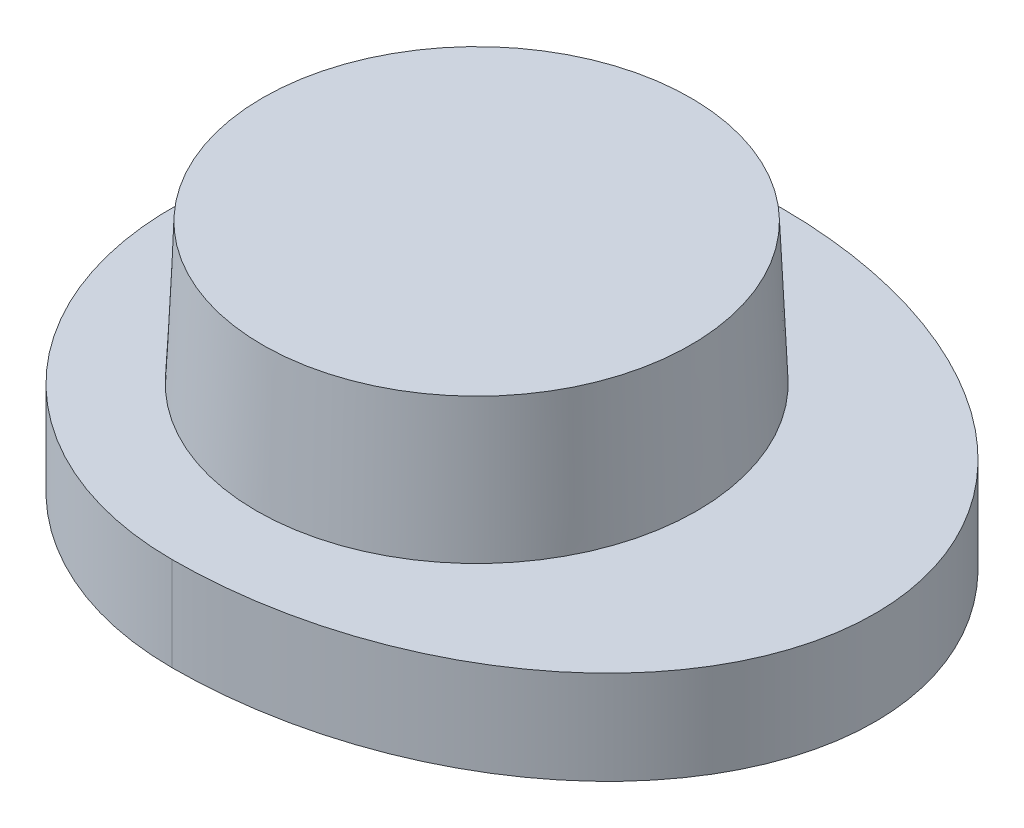
from build123d import *

# Parameters (mm, degrees)
BOSS_EXTRUDE4_DEPTH = 2.000034
SCALE1_SCALE        = 0.854545455


with BuildPart() as part:
    # Sketch1 one side → Revolve25 (revolve)
    with BuildSketch(Plane.XY):
        Polygon((-4.528744292, -19.623960417), (-4.7, 0), (-6.5, 0), (-6.5, -2), (-5.582580535, -2), (-5.425496915, -20), (-2.35, -23.075496915), (-2.35, -24.575496915), (-1.45, -24.575496915), (-1.45, -22.702704709), align=None)
        Polygon((-5.6, -0.9), (-5.59218009, -0.9), (-5.590434716, -1.1), (-5.6, -1.1), align=None, mode=Mode.SUBTRACT)
    revolve(axis=Axis((0, 0, 0), (0, -1, 0)))


with BuildPart() as body_2:
    # Sketch1_10 → Revolve31 (revolve)
    with BuildSketch(Plane.XY):
        Polygon((26.569018636, 2.999966443), (22, 2.999966443), (22, 1.999966443), (26, 1.999966443), (26, -2.000033557), (28.5, -2.000033557), (28.5, 0), (26.7, 0), align=None)
    revolve(axis=Axis((22, 17.95552364, 0), (0, -1, 0)))

    # Sketch2 → Boss-Extrude4 (add)
    with BuildSketch(Plane(origin=(0, -2.000033557, 0), x_dir=(-1, 0, 0), z_dir=(0, -1, 0))):
        with BuildLine():
            Line((-22, 4), (-22, 6.5))
            add(Edge.make_bspline(
                [(-22, 6.5), (-30.5, 6.5), (-30.5, 0), (-30.5, -6.5), (-22, -6.5)],
                knots=[1.570796327, 1.570796327, 1.570796327, 3.141592654, 3.141592654, 4.71238898, 4.71238898, 4.71238898], degree=2, weights=[1, 0.707106781, 1, 0.707106781, 1]))
            Line((-22, -6.5), (-22, -4))
            ThreePointArc((-22, -4), (-26, 0), (-22, 4))
        make_face()
    extrude(amount=-BOSS_EXTRUDE4_DEPTH)


with BuildPart() as body_2_1:
    # Scale1: scaled about (22.846218841, -0.018057413, 0)
    add(body_2.part.scale(SCALE1_SCALE).moved(Location((3.323086377, -0.002626533, 0))))


solid = body_2_1.part
